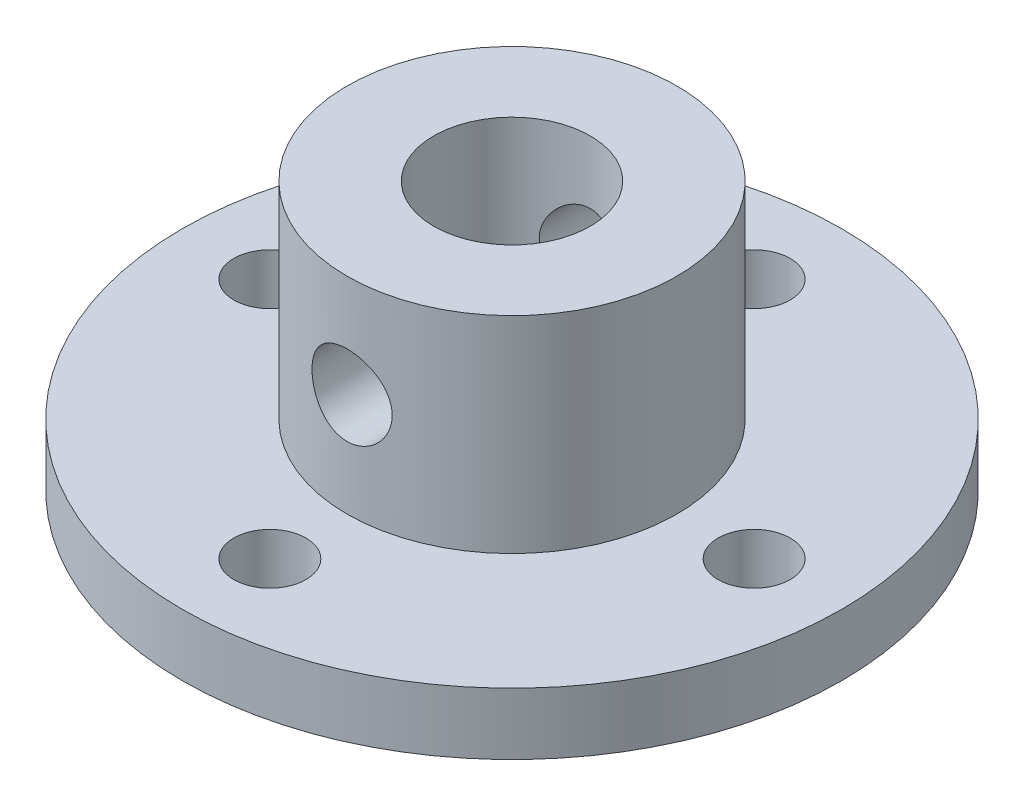
from build123d import *

# Parameters (mm, degrees)
SKETCH1_R               = 16
SKETCH1_R_2             = 1.75
SKETCH1_R_3             = 8
BOSS_EXTRUDE1_DEPTH     = 3
SKETCH1_3_R             = 8
SKETCH1_3_R_2           = 3.8
BOSS_EXTRUDE2_DEPTH     = 13
CUT_EXTRUDE1_DEPTH      = 27.095976701
CUT_EXTRUDE1_DEPTH_BACK = 27.095976701
SKETCH2_R               = 1.944334414


with BuildPart() as part:
    # Sketch1 → Boss-Extrude1 (new body)
    with BuildSketch(Plane(origin=(0, 0, 0), x_dir=(1, 0, 0), z_dir=(0, 1, 0))):
        Circle(SKETCH1_R)
        with Locations((-11.75, 0)):
            Circle(SKETCH1_R_2, mode=Mode.SUBTRACT)
        with Locations((0, -11.75)):
            Circle(SKETCH1_R_2, mode=Mode.SUBTRACT)
        Circle(SKETCH1_R_3, mode=Mode.SUBTRACT)
        with Locations((11.75, 0)):
            Circle(SKETCH1_R_2, mode=Mode.SUBTRACT)
        with Locations((0, 11.75)):
            Circle(SKETCH1_R_2, mode=Mode.SUBTRACT)
    extrude(amount=BOSS_EXTRUDE1_DEPTH)

    # Sketch1_3 → Boss-Extrude2 (add)
    with BuildSketch(Plane(origin=(0, 0, 0), x_dir=(1, 0, 0), z_dir=(0, 1, 0))):
        Circle(SKETCH1_3_R)
        Circle(SKETCH1_3_R_2, mode=Mode.SUBTRACT)
    extrude(amount=BOSS_EXTRUDE2_DEPTH)

    # Sketch2 → Cut-Extrude1 (cut, two sides: drawn at the far end of the back side and taken through both)
    with BuildSketch(Plane.XY.offset(-CUT_EXTRUDE1_DEPTH_BACK)):
        with Locations((0, 8)):
            Circle(SKETCH2_R)
    extrude(amount=CUT_EXTRUDE1_DEPTH + CUT_EXTRUDE1_DEPTH_BACK, mode=Mode.SUBTRACT)


solid = part.part
